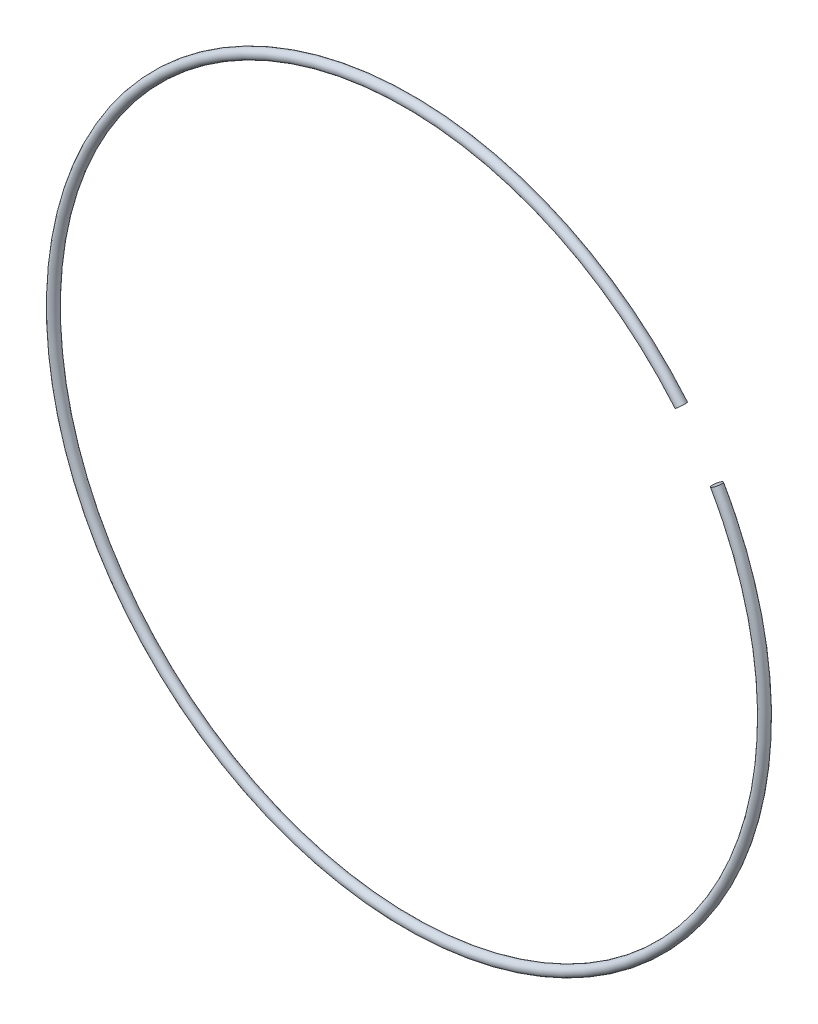
from build123d import *

# Parameters (mm, degrees)
SKETCH2_R = 1.5875


with BuildPart() as part:
    # Sweep1: sweep along a path in Sketch1
    with BuildLine(Plane.XY) as sweep1_path:
        ThreePointArc((87.558879848, 73.470623787), (-93.629078662, -65.559786675), (98.986703653, 57.15))
    # Sketch2 → Sweep1 (sweep)
    with BuildSketch(Plane(origin=(87.558879848, 73.470623787, 0), x_dir=(0.766044443, 0.64278761, 0), z_dir=(-0.64278761, 0.766044443, 0))):
        Circle(SKETCH2_R)
    sweep(path=sweep1_path.line)


solid = part.part
